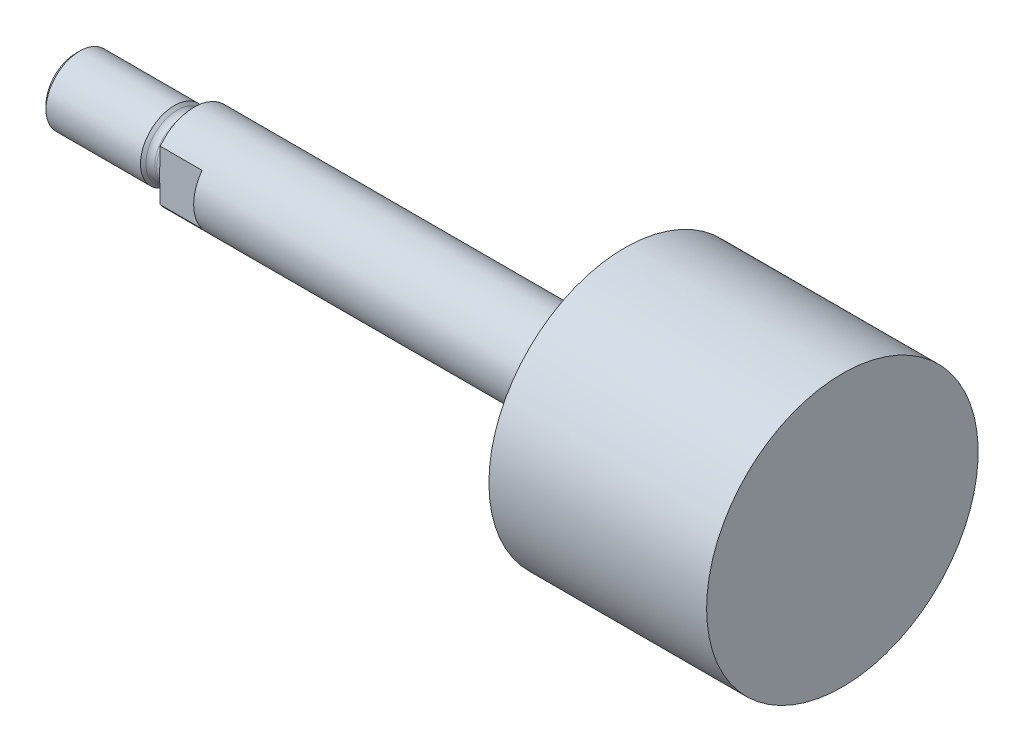
from build123d import *

# Parameters (mm, degrees)
SKETCH3_W          = 31.75
SKETCH3_H          = 31.75
SKETCH3_W_2        = 12.7
SKETCH3_H_2        = 15.875
CUT_EXTRUDE1_DEPTH = 8.509


with BuildPart() as part:
    # Sketch1 → Revolve1 (revolve)
    with BuildSketch(Plane.XY):
        Polygon((-9.525, 0), (-9.525, 7.9375), (71.4248, 7.9375), (71.4248, 25.52065), (112.3442, 25.52065), (112.3442, 0), align=None)
    revolve(axis=Axis((112.3442, 0, 0), (-1, 0, 0)))

    # Sketch2 → Revolve2 (revolve)
    with BuildSketch(Plane.XY):
        with BuildLine():
            Line((-31.75, 0), (-31.75, 5.59435))
            Line((-31.75, 5.59435), (-30.99435, 6.35))
            Line((-30.99435, 6.35), (-13.2334, 6.35))
            Line((-13.2334, 6.35), (-12.726366704, 5.842966704))
            ThreePointArc((-12.726366704, 5.842966704), (-12.190743755, 5.485074892), (-11.558933409, 5.3594))
            Line((-11.558933409, 5.3594), (-11.176, 5.3594))
            ThreePointArc((-11.176, 5.3594), (-10.008566704, 5.842966704), (-9.525, 7.0104))
            Line((-9.525, 7.0104), (-9.525, 0))
            Line((-9.525, 0), (-31.75, 0))
        make_face()
    revolve(axis=Axis((-9.525, 0, 0), (-1, 0, 0)))

    # Sketch3 → Cut-Extrude1 (cut)
    with BuildSketch(Plane(origin=(-10.16, 0, 0), x_dir=(0, 0, -1), z_dir=(1, 0, 0))):
        Rectangle(SKETCH3_W, SKETCH3_H)
        Rectangle(SKETCH3_W_2, SKETCH3_H_2, mode=Mode.SUBTRACT)
    extrude(amount=CUT_EXTRUDE1_DEPTH, mode=Mode.SUBTRACT)


solid = part.part
